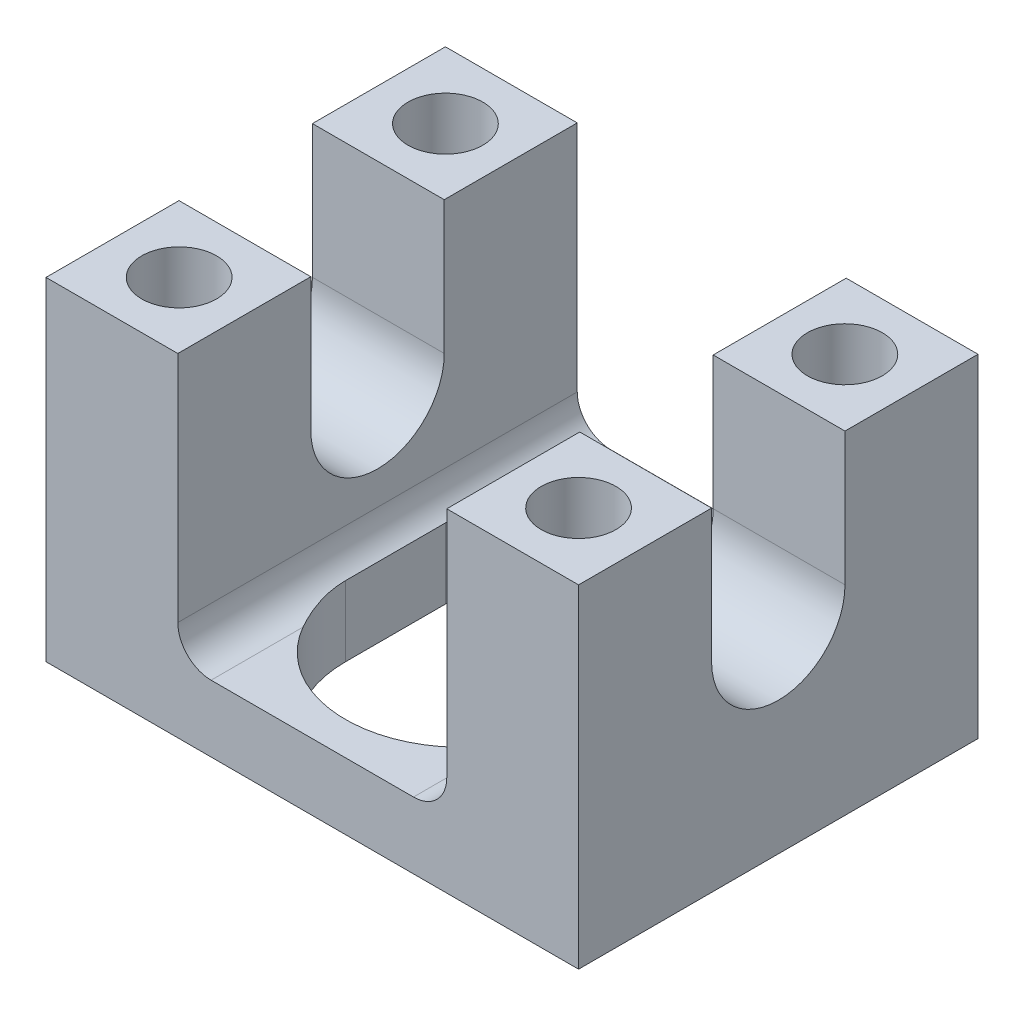
from build123d import *

# Parameters (mm, degrees)
EXTRUDE1_DEPTH          = 19.05
CUT_EXTRUDE1_DEPTH      = 51.8
FILLET1_R               = 3.175
CUT_EXTRUDE2_DEPTH      = 2.54
CUT_EXTRUDE2_DEPTH_BACK = 7.35
SKETCH4_R               = 3.5687
CUT_EXTRUDE3_DEPTH      = 32.7500001


with BuildPart() as part:
    # Sketch1 → Extrude1 (new body, symmetric)
    with BuildSketch(Plane.XY):
        Polygon((25.4, 15.875), (12.827, 15.875), (12.827, -9.525), (-12.827, -9.525), (-12.827, 15.875), (-25.4, 15.875), (-25.4, -15.875), (25.4, -15.875), align=None)
    extrude(amount=EXTRUDE1_DEPTH, both=True)

    # Sketch2 → Cut-Extrude1 (cut, through all)
    with BuildSketch(Plane.ZY.offset(25.4)):
        with BuildLine():
            Line((-6.3627, 15.875), (-6.3627, 3.175))
            ThreePointArc((-6.3627, 3.175), (0, -3.1877), (6.3627, 3.175))
            Line((6.3627, 3.175), (6.3627, 15.875))
            Line((6.3627, 15.875), (-6.3627, 15.875))
        make_face()
    extrude(amount=-CUT_EXTRUDE1_DEPTH, mode=Mode.SUBTRACT)

    # Fillet1
    fillet1_edges = [part.edges().sort_by_distance(p)[0] for p in [
        (-12.827, -9.525, 0),
        (12.827, -9.525, 0),
    ]]
    fillet(fillet1_edges, radius=FILLET1_R)

    # Sketch3 → Cut-Extrude2 (cut, two sides)
    with BuildSketch(Plane(origin=(0, -9.525, 0), x_dir=(-1, 0, 0), z_dir=(0, 1, 0))) as cut_extrude2_sk:
        with BuildLine():
            Line((-11.1125, 4.7752), (-11.1125, -4.7752))
            ThreePointArc((-11.1125, -4.7752), (0, -15.8877), (11.1125, -4.7752))
            Line((11.1125, -4.7752), (11.1125, 4.7752))
            ThreePointArc((11.1125, 4.7752), (0, 15.8877), (-11.1125, 4.7752))
        make_face()
    extrude(amount=CUT_EXTRUDE2_DEPTH, mode=Mode.SUBTRACT)
    extrude(cut_extrude2_sk.sketch, amount=-CUT_EXTRUDE2_DEPTH_BACK, mode=Mode.SUBTRACT)

    # Sketch4 → Cut-Extrude3 (cut, through all)
    with BuildSketch(Plane(origin=(0, 15.875, 0), x_dir=(-1, 0, 0), z_dir=(0, 1, 0))):
        with Locations(Location((-19.05, -12.7, 0), (0, 0, 90))):  # turned: the seam where the file's is
            Circle(SKETCH4_R)
        with Locations(Location((-19.05, 12.7, 0), (0, 0, 90))):  # turned: the seam where the file's is
            Circle(SKETCH4_R)
        with Locations(Location((19.05, 12.7, 0), (0, 0, 90))):  # turned: the seam where the file's is
            Circle(SKETCH4_R)
        with Locations(Location((19.05, -12.7, 0), (0, 0, 90))):  # turned: the seam where the file's is
            Circle(SKETCH4_R)
    extrude(amount=-CUT_EXTRUDE3_DEPTH, mode=Mode.SUBTRACT)


solid = part.part
